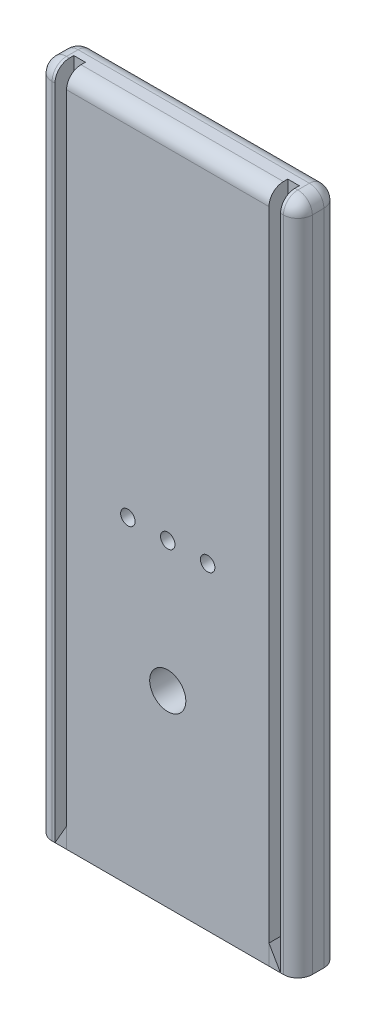
from build123d import *

# Parameters (mm, degrees)
SKETCH1_W             = 114.3
SKETCH1_H             = 295.275
BOSS_EXTRUDE1_DEPTH   = 8.89
SKETCH2_R             = 3.175
CUT_EXTRUDE1_DEPTH    = 12.7
SKETCH3_W             = 5.08
SKETCH3_H             = 8.255
CUT_EXTRUDE2_DEPTH    = 296.275
FILLET1_R             = 6.35
SKETCH5_R             = 7.9375
CUT_EXTRUDE4_DEPTH    = 18.78
BOSS_EXTRUDE5_DEPTH   = 8.255
BOSS_EXTRUDE5_2_DEPTH = 8.255


with BuildPart() as part:
    # Sketch1 → Boss-Extrude1 (new body, symmetric)
    with BuildSketch(Plane.XY):
        Rectangle(SKETCH1_W, SKETCH1_H)
    extrude(amount=BOSS_EXTRUDE1_DEPTH, both=True)

    # Sketch2 → Cut-Extrude1 (cut)
    with BuildSketch(Plane.XY.offset(8.89)):
        with Locations((0, -7.9375)):
            Circle(SKETCH2_R)
        with Locations((-17.526, -7.9375)):
            Circle(SKETCH2_R)
        with Locations((17.526, -7.9375)):
            Circle(SKETCH2_R)
    extrude(amount=-CUT_EXTRUDE1_DEPTH, mode=Mode.SUBTRACT)

    # Sketch3 → Cut-Extrude2 (cut, through all)
    with BuildSketch(Plane(origin=(0, 147.6375, 0), x_dir=(1, 0, 0), z_dir=(0, 1, 0))):
        with Locations((-46.99, -4.7625)):
            Rectangle(SKETCH3_W, SKETCH3_H)
    cut_extrude2 = extrude(amount=-CUT_EXTRUDE2_DEPTH, mode=Mode.SUBTRACT)

    # Mirror1: Cut-Extrude2 across plane
    add(cut_extrude2.mirror(Plane(origin=(0, 0, 0), x_dir=(0, 0, 1), z_dir=(1, 0, 0))), mode=Mode.SUBTRACT)

    # Fillet1
    fillet1_edges = [part.edges().sort_by_distance(p)[0] for p in [
        (-57.15, 0, 8.89),
        (-53.34, 147.6375, 8.89),
        (57.15, 0, 8.89),
        (0, 147.6375, 8.89),
        (-57.15, 0, -8.89),
        (0, 147.6375, -8.89),
        (57.15, 0, -8.89),
        (53.34, 147.6375, 8.89),
        (-57.15, 147.6375, 0),
        (57.15, 147.6375, 0),
    ]]
    fillet(fillet1_edges, radius=FILLET1_R)

    # Sketch5 → Cut-Extrude4 (cut, through all)
    with BuildSketch(Plane.XY.offset(8.89)):
        with Locations((0, -65.0875)):
            Circle(SKETCH5_R)
    extrude(amount=-CUT_EXTRUDE4_DEPTH, mode=Mode.SUBTRACT)


with BuildPart() as body_2:
    # Sketch6 → Boss-Extrude5 (new body)
    with BuildSketch(Plane.XY.offset(0.635)):
        Polygon((-49.53, -147.6375), (-44.45, -138.84082047), (-44.45, -147.6375), align=None)
    extrude(amount=BOSS_EXTRUDE5_DEPTH)


with BuildPart() as body_3:
    # Sketch6 → Boss-Extrude5 2 (new body)
    with BuildSketch(Plane.XY.offset(0.635)):
        Polygon((49.53, -147.6375), (44.45, -138.84082047), (44.45, -147.6375), align=None)
    extrude(amount=BOSS_EXTRUDE5_2_DEPTH)


solid = Compound([part.part, body_2.part, body_3.part])
